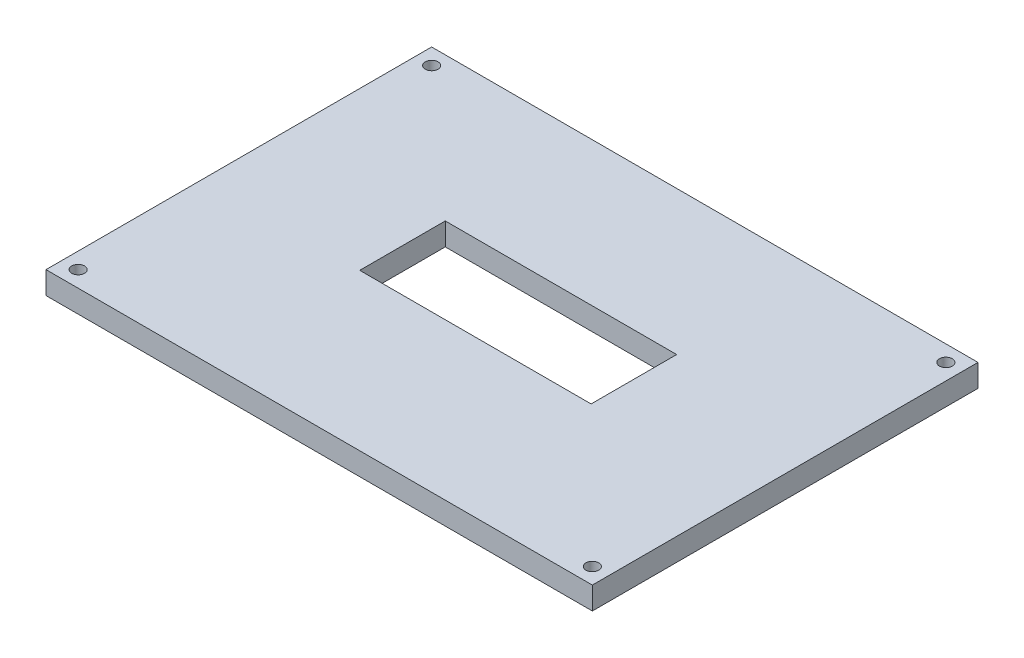
from build123d import *

# Parameters (mm, degrees)
SKETCH1_W           = 170
SKETCH1_H           = 120
BOSS_EXTRUDE1_DEPTH = 7
SKETCH2_W           = 72
SKETCH2_H           = 26.620567464
CUT_EXTRUDE1_DEPTH  = 7
SKETCH3_R           = 2
CUT_EXTRUDE5_DEPTH  = 7
SKETCH7_R           = 2
CUT_EXTRUDE7_DEPTH  = 10
SKETCH6_R           = 2
CUT_EXTRUDE10_DEPTH = 10
SKETCH9_R           = 2
CUT_EXTRUDE11_DEPTH = 10


with BuildPart() as part:
    # Sketch1 → Boss-Extrude1 (new body)
    with BuildSketch(Plane(origin=(0, 0, 0), x_dir=(1, 0, 0), z_dir=(0, 1, 0))):
        Rectangle(SKETCH1_W, SKETCH1_H)
    extrude(amount=BOSS_EXTRUDE1_DEPTH)

    # Sketch2 → Cut-Extrude1 (cut)
    with BuildSketch(Plane(origin=(0, 7, 0), x_dir=(1, 0, 0), z_dir=(0, 1, 0))):
        with Locations((0, 1.926488435)):
            Rectangle(SKETCH2_W, SKETCH2_H)
    extrude(amount=-CUT_EXTRUDE1_DEPTH, mode=Mode.SUBTRACT)

    # Sketch3 → Cut-Extrude5 (cut)
    with BuildSketch(Plane(origin=(0, 7, 0), x_dir=(1, 0, 0), z_dir=(0, 1, 0))):
        with Locations((-80, 55)):
            Circle(SKETCH3_R)
    extrude(amount=-CUT_EXTRUDE5_DEPTH, mode=Mode.SUBTRACT)

    # Sketch7 → Cut-Extrude7 (cut)
    with BuildSketch(Plane(origin=(0, 7, 0), x_dir=(1, 0, 0), z_dir=(0, 1, 0))):
        with Locations((-80, -55)):
            Circle(SKETCH7_R)
    extrude(amount=-CUT_EXTRUDE7_DEPTH, mode=Mode.SUBTRACT)

    # Sketch6 → Cut-Extrude10 (cut)
    with BuildSketch(Plane(origin=(0, 7, 0), x_dir=(1, 0, 0), z_dir=(0, 1, 0))):
        with Locations((80, 55)):
            Circle(SKETCH6_R)
    extrude(amount=-CUT_EXTRUDE10_DEPTH, mode=Mode.SUBTRACT)

    # Sketch9 → Cut-Extrude11 (cut)
    with BuildSketch(Plane(origin=(0, 7, 0), x_dir=(1, 0, 0), z_dir=(0, 1, 0))):
        with Locations((80, -55)):
            Circle(SKETCH9_R)
    extrude(amount=-CUT_EXTRUDE11_DEPTH, mode=Mode.SUBTRACT)


solid = part.part
